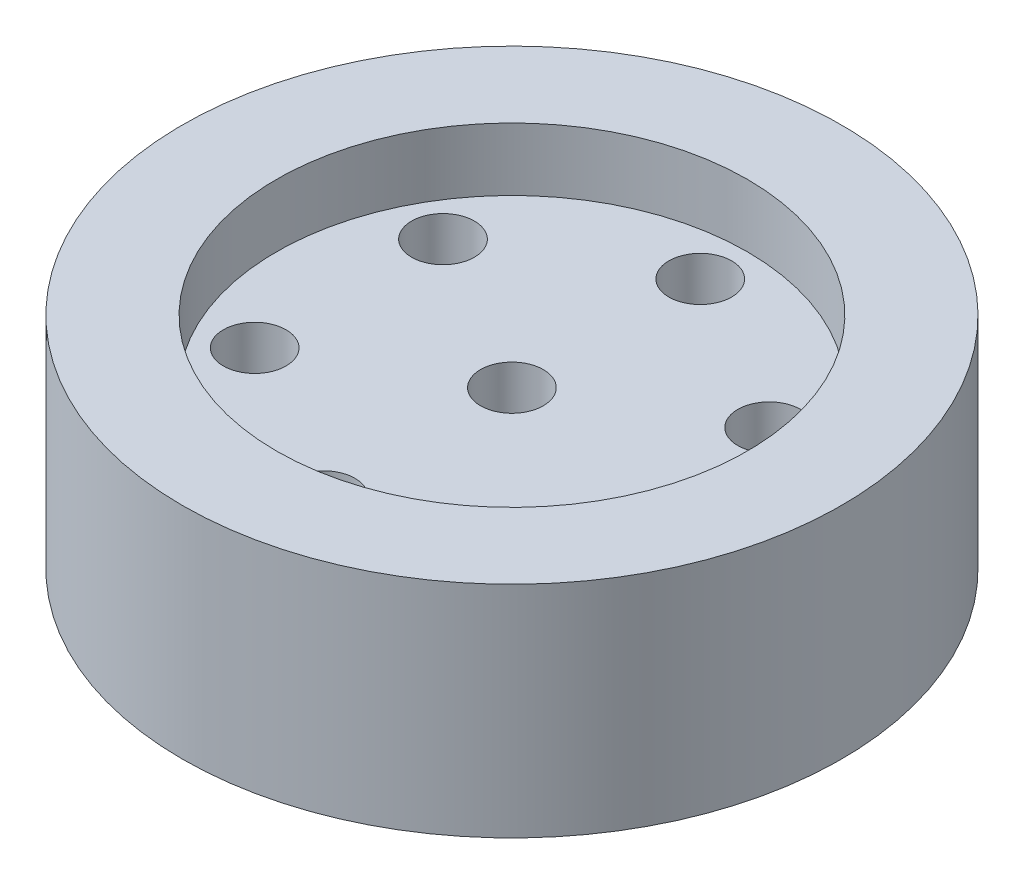
from build123d import *

# Parameters (mm, degrees)
SKETCH1_R           = 21
BOSS_EXTRUDE1_DEPTH = 14
SKETCH2_R           = 15
CUT_EXTRUDE1_DEPTH  = 4
SKETCH3_R           = 19
SKETCH3_R_2         = 5
CUT_EXTRUDE2_DEPTH  = 4
SKETCH4_R           = 2
CUT_EXTRUDE3_DEPTH  = 15
SKETCH5_R           = 2
CUT_EXTRUDE4_DEPTH  = 11


with BuildPart() as part:
    # Sketch1 → Boss-Extrude1 (new body)
    with BuildSketch(Plane(origin=(0, 0, 0), x_dir=(1, 0, 0), z_dir=(0, 1, 0))):
        Circle(SKETCH1_R)
    extrude(amount=BOSS_EXTRUDE1_DEPTH)

    # Sketch2 → Cut-Extrude1 (cut)
    with BuildSketch(Plane(origin=(0, 14, 0), x_dir=(1, 0, 0), z_dir=(0, 1, 0))):
        Circle(SKETCH2_R)
    extrude(amount=-CUT_EXTRUDE1_DEPTH, mode=Mode.SUBTRACT)

    # Sketch3 → Cut-Extrude2 (cut)
    with BuildSketch(Plane.XZ):
        Circle(SKETCH3_R)
        Circle(SKETCH3_R_2, mode=Mode.SUBTRACT)
    extrude(amount=-CUT_EXTRUDE2_DEPTH, mode=Mode.SUBTRACT)

    # Sketch4 → Cut-Extrude3 (cut, through all)
    with BuildSketch(Plane.XZ):
        Circle(SKETCH4_R)
    extrude(amount=-CUT_EXTRUDE3_DEPTH, mode=Mode.SUBTRACT)

    # Sketch5 → Cut-Extrude4 (cut, through all)
    with BuildSketch(Plane.XZ.offset(-4)):
        with Locations((0, 12)):
            Circle(SKETCH5_R)
        with Locations((10.392304845, 6)):
            Circle(SKETCH5_R)
        with Locations((10.392304845, -6)):
            Circle(SKETCH5_R)
        with Locations((0, -12)):
            Circle(SKETCH5_R)
        with Locations((-10.392304845, -6)):
            Circle(SKETCH5_R)
        with Locations((-10.392304845, 6)):
            Circle(SKETCH5_R)
    extrude(amount=-CUT_EXTRUDE4_DEPTH, mode=Mode.SUBTRACT)


solid = part.part
